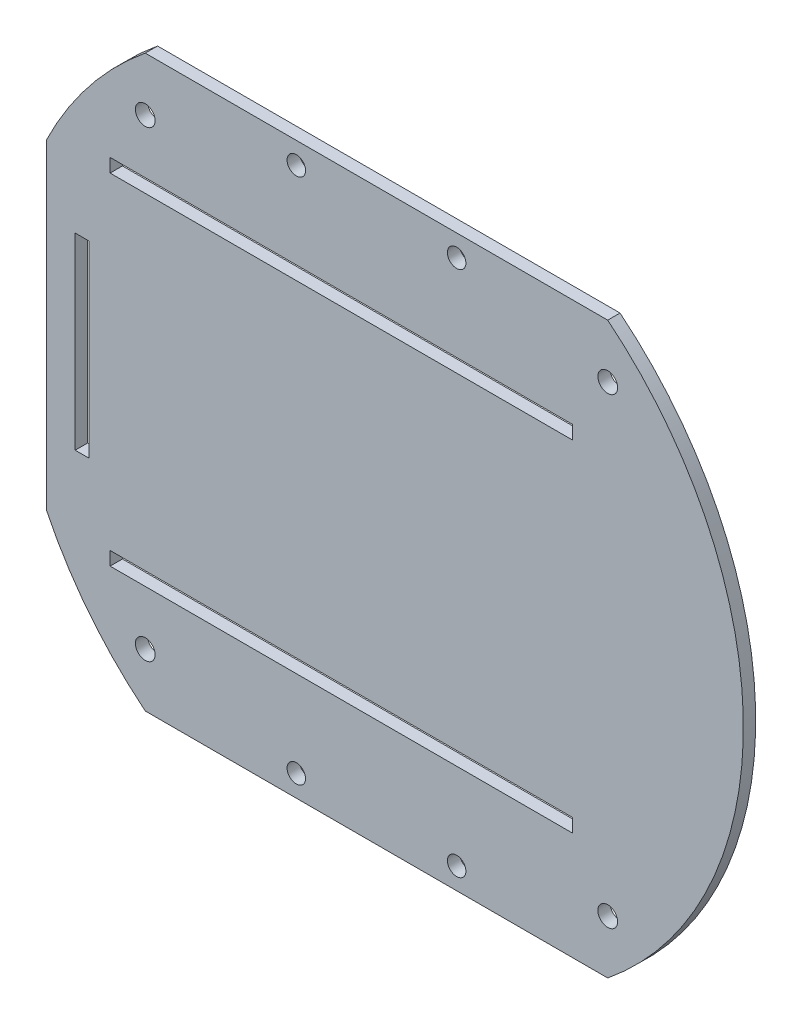
from build123d import *

# Parameters (mm, degrees)
SKIZZE1_R                       = 59.5
AUFSATZ_LINEAR_AUSTRAGEN1_DEPTH = 2
SKIZZE2_R                       = 1.6
SKIZZE2_W                       = 75
SKIZZE2_H                       = 2.2
SKIZZE2_W_2                     = 2.2
SKIZZE2_H_2                     = 30.5
SCHNITT_LINEAR_AUSTRAGEN1_DEPTH = 2
SKIZZE3_R                       = 1.5
SKIZZE3_W                       = 75
SKIZZE3_H                       = 13.30476215
SKIZZE3_W_2                     = 5.981311675
SKIZZE3_H_2                     = 52
SCHNITT_LINEAR_AUSTRAGEN2_DEPTH = 2


with BuildPart() as part:
    # Skizze1 → Aufsatz-Linear austragen1 (new body)
    with BuildSketch(Plane.XY):
        Circle(SKIZZE1_R)
    extrude(amount=AUFSATZ_LINEAR_AUSTRAGEN1_DEPTH)

    # Skizze2 → Schnitt-Linear austragen1 (cut)
    with BuildSketch(Plane.XY.offset(2)):
        with Locations((37.5, -37.5)):
            Circle(SKIZZE2_R)
        with Locations((-37.5, -37.5)):
            Circle(SKIZZE2_R)
        with Locations((-37.5, 37.5)):
            Circle(SKIZZE2_R)
        with Locations((37.5, 37.5)):
            Circle(SKIZZE2_R)
        with Locations((-5.697175449, 27.6)):
            Rectangle(SKIZZE2_W, SKIZZE2_H)
        with Locations((-5.697175449, -27.6)):
            Rectangle(SKIZZE2_W, SKIZZE2_H)
        with Locations((-47.758902381, 0)):
            Rectangle(SKIZZE2_W_2, SKIZZE2_H_2)
    extrude(amount=-SCHNITT_LINEAR_AUSTRAGEN1_DEPTH, mode=Mode.SUBTRACT)

    # Skizze3 → Schnitt-Linear austragen2 (cut)
    with BuildSketch(Plane.XY.offset(2)):
        with Locations((-13, -42.7)):
            Circle(SKIZZE3_R)
        with Locations((13, -42.7)):
            Circle(SKIZZE3_R)
        with Locations((-13, 42.7)):
            Circle(SKIZZE3_R)
        with Locations((13, 42.7)):
            Circle(SKIZZE3_R)
        with Locations((0, 52.847618925)):
            Rectangle(SKIZZE3_W, SKIZZE3_H)
        with Locations((0, -52.847618925)):
            Rectangle(SKIZZE3_W, SKIZZE3_H)
        with Locations((-56.509344163, 0)):
            Rectangle(SKIZZE3_W_2, SKIZZE3_H_2)
    extrude(amount=-SCHNITT_LINEAR_AUSTRAGEN2_DEPTH, mode=Mode.SUBTRACT)


solid = part.part
